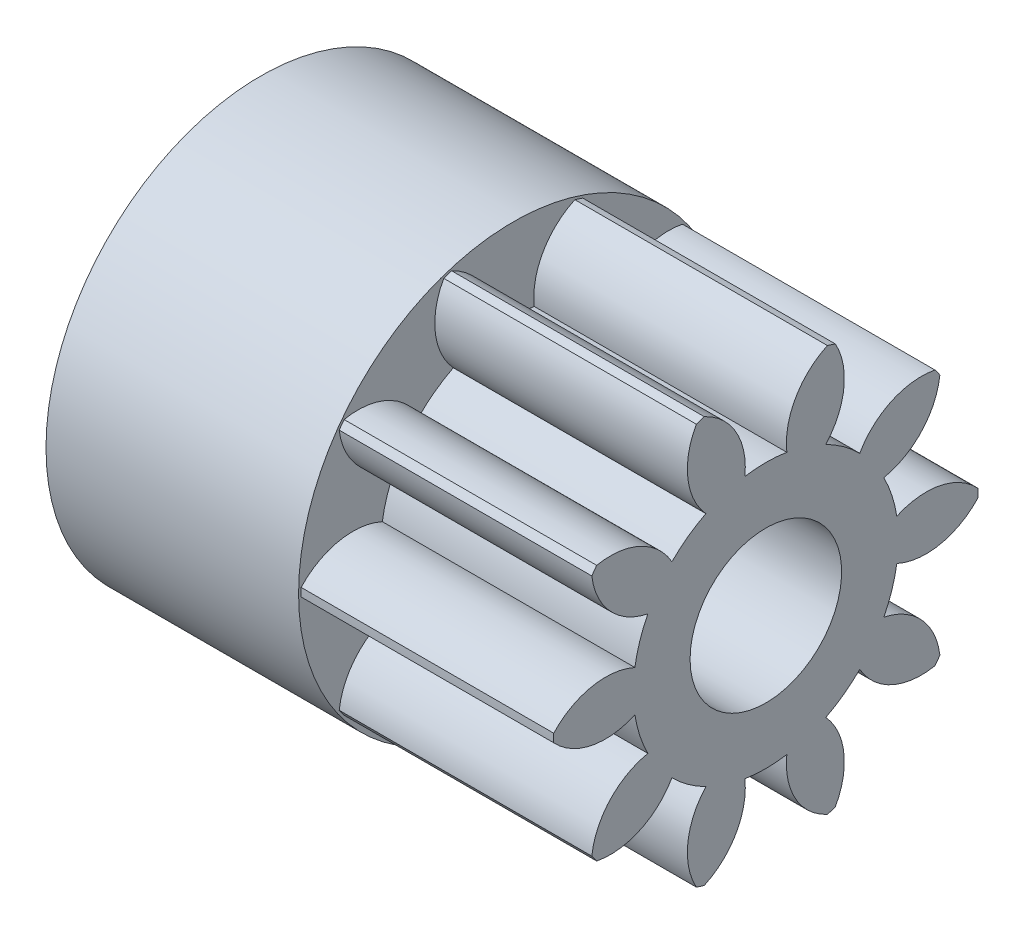
from build123d import *

# Parameters (mm, degrees)
BASPROSKE_W             = 5
BASPROSKE_H             = 4.2
TOOTHCUT_DEPTH          = 8.764019578
TEETHCUTS_COUNT         = 10
TEETHCUTS_ANGLE         = 324
BORSKE_R                = 1.5
BORE_DEPTH              = 50.0000508
CROQUIS1_R              = 4.25
CROQUIS1_R_2            = 3.25
SALIENTE_EXTRUIR1_DEPTH = 5
CROQUIS2_R              = 3.25
SALIENTE_EXTRUIR2_DEPTH = 2
SALIENTE_EXTRUIR3_DEPTH = 2


with BuildPart() as part:
    # BasProSke → Base-Revolve (revolve)
    with BuildSketch(Plane(origin=(0, 0, 0), x_dir=(1, 0, 0), z_dir=(0, 1, 0)), mode=Mode.PRIVATE) as base_revolve_sk:
        with Locations((2.5, 2.1)):
            Rectangle(BASPROSKE_W, BASPROSKE_H)
    revolve(base_revolve_sk.sketch.rotate(Axis((-10, 0, 0), (1, 0, 0)), 180), axis=Axis((-10, 0, 0), (1, 0, 0)))

    # TooCutSke → ToothCut (cut, through all)
    with BuildSketch(Plane(origin=(0, 0, 0), x_dir=(0, 0, -1), z_dir=(1, 0, 0))):
        with BuildLine():
            ThreePointArc((0.415506654, 2.590893711), (0, 2.624), (-0.415506654, 2.590893711))
            ThreePointArc((-0.415506654, 2.590893711), (-0.596160737, 3.451685568), (-1.254578949, 4.034852763))
            ThreePointArc((-1.254578949, 4.034852763), (0, 4.2254), (1.254578949, 4.034852763))
            ThreePointArc((1.254578949, 4.034852763), (0.596160737, 3.451685568), (0.415506654, 2.590893711))
        make_face()
    toothcut = extrude(amount=TOOTHCUT_DEPTH, mode=Mode.SUBTRACT)

    # TeethCuts: ToothCut ×10 about axis
    teethcuts_axis = Axis((-10, 0, 0), (1, 0, 0))
    for i in range(1, TEETHCUTS_COUNT):
        add(toothcut.rotate(teethcuts_axis, i * TEETHCUTS_ANGLE / (TEETHCUTS_COUNT - 1)), mode=Mode.SUBTRACT)

    # BorSke → Bore (cut, symmetric)
    with BuildSketch(Plane(origin=(0, 0, 0), x_dir=(0, 0, -1), z_dir=(1, 0, 0))):
        with Locations(Location((0, 0, 0), (0, 0, 180))):
            Circle(BORSKE_R)
    extrude(amount=BORE_DEPTH, both=True, mode=Mode.SUBTRACT)

    # Croquis1 → Saliente-Extruir1 (add)
    with BuildSketch(Plane.ZY):
        Circle(CROQUIS1_R)
        with Locations(Location((0, 0, 0), (0, 0, 189.396976621))):
            Circle(CROQUIS1_R_2, mode=Mode.SUBTRACT)
    extrude(amount=SALIENTE_EXTRUIR1_DEPTH)

    # Croquis2 → Saliente-Extruir2 (add)
    with BuildSketch(Plane.ZY):
        Circle(CROQUIS2_R)
    extrude(amount=SALIENTE_EXTRUIR2_DEPTH)

    # Croquis3 → Saliente-Extruir3 (add)
    with BuildSketch(Plane.ZY.offset(2)):
        with BuildLine():
            Line((-1.5, 2.883140649), (-1.5, -2.883140649))
            ThreePointArc((-1.5, -2.883140649), (-3.25, 0), (-1.5, 2.883140649))
        make_face()
    extrude(amount=SALIENTE_EXTRUIR3_DEPTH)


solid = part.part
